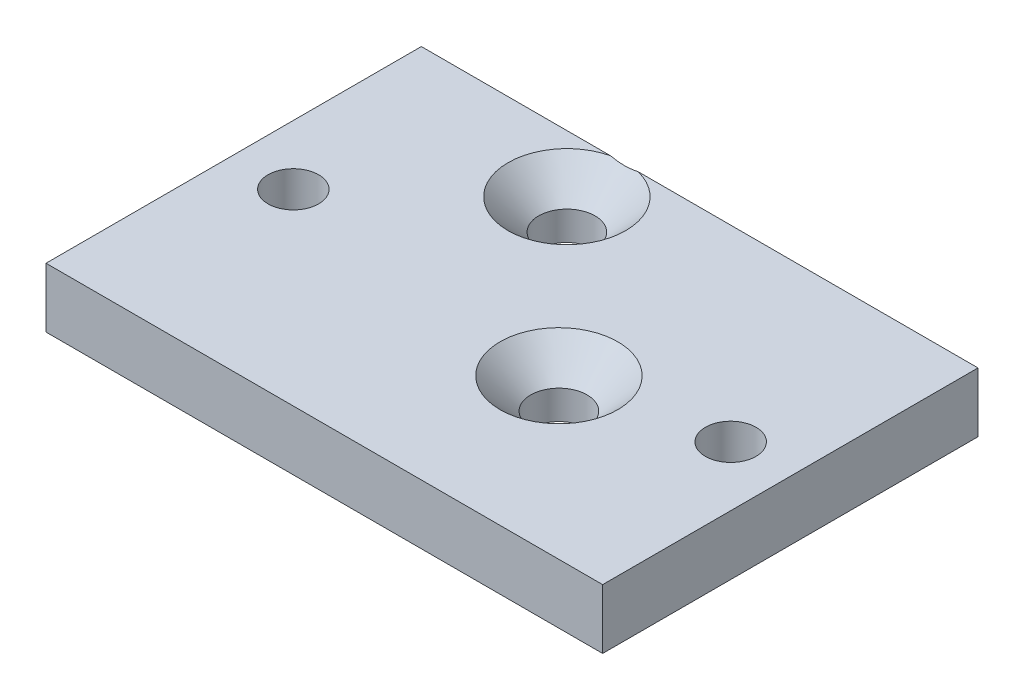
from build123d import *

# Parameters (mm, degrees)
SKETCH1_W                                       = 44.45
SKETCH1_H                                       = 29.972
EXTRUDE1_DEPTH                                  = 4.7625
F_10_32_TAPPED_HOLE1_D                          = 4.0386
CSK_FOR_M4_FLAT_HEAD_MACHINE_SCREW1_D           = 4.5
CSK_FOR_M4_FLAT_HEAD_MACHINE_SCREW1_CSINK_D     = 9.4
CSK_FOR_M4_FLAT_HEAD_MACHINE_SCREW1_CSINK_ANGLE = 90


with BuildPart() as part:
    # Sketch1 → Extrude1 (new body)
    with BuildSketch(Plane(origin=(0, 0, 0), x_dir=(1, 0, 0), z_dir=(0, 1, 0))):
        with Locations((22.225, 14.986)):
            Rectangle(SKETCH1_W, SKETCH1_H)
    extrude(amount=EXTRUDE1_DEPTH)

    # #10-32 Tapped Hole1 (through all)
    with Locations(Plane(origin=(0, 4.7625, 0), x_dir=(-1, 0, 0), z_dir=(0, 1, 0))):
        with Locations((-4.7625, -14.986), (-39.6875, -14.986)):
            Hole(F_10_32_TAPPED_HOLE1_D / 2)

    # CSK for M4 Flat Head Machine Screw1 (through all)
    with Locations(Plane(origin=(0, 4.7625, 0), x_dir=(-1, 0, 0), z_dir=(0, 1, 0))):
        with Locations((-28.2575, -12.7), (-16.1925, -25.4)):
            CounterSinkHole(CSK_FOR_M4_FLAT_HEAD_MACHINE_SCREW1_D / 2, CSK_FOR_M4_FLAT_HEAD_MACHINE_SCREW1_CSINK_D / 2, counter_sink_angle=CSK_FOR_M4_FLAT_HEAD_MACHINE_SCREW1_CSINK_ANGLE)


solid = part.part
